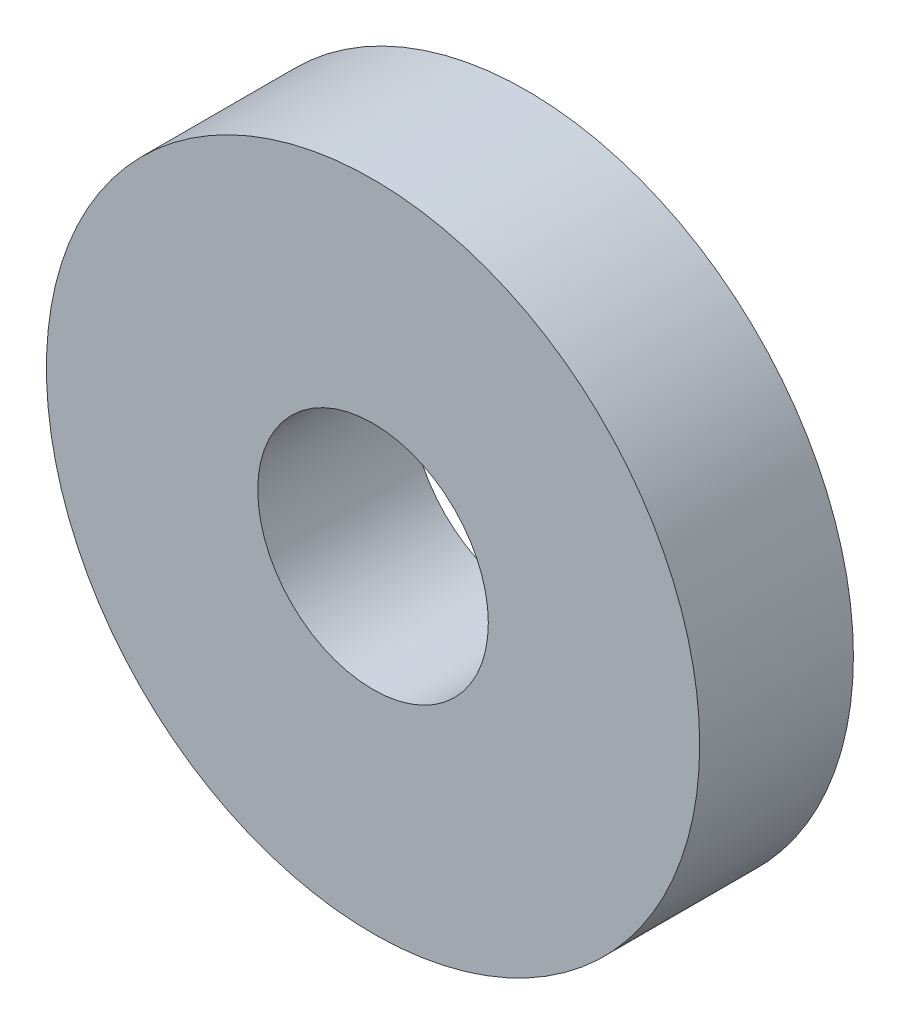
from build123d import *

# Parameters (mm, degrees)
SKETCH1_R           = 8.5
SKETCH1_R_2         = 3
BOSS_EXTRUDE1_DEPTH = 4


with BuildPart() as part:
    # Sketch1 → Boss-Extrude1 (new body)
    with BuildSketch(Plane.XY):
        Circle(SKETCH1_R)
        Circle(SKETCH1_R_2, mode=Mode.SUBTRACT)
    extrude(amount=BOSS_EXTRUDE1_DEPTH)


solid = part.part
